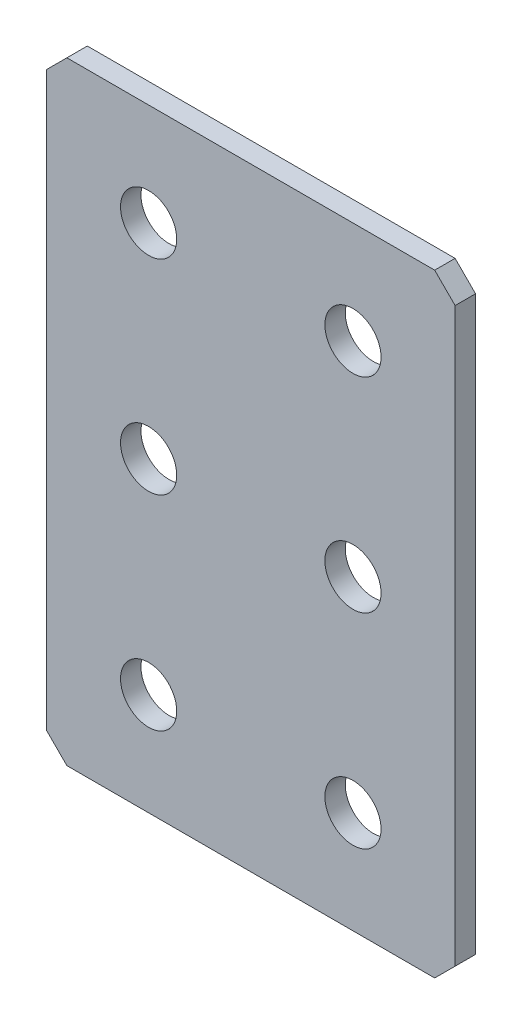
from build123d import *

# Parameters (mm, degrees)
SKETCH_1_W        = 40
SKETCH_1_H        = 60
EXTRUDE_1_DEPTH   = 2
CHAMFER_1_SIZE    = 2
HOLE_WIZARD_M51_D = 5.5


with BuildPart() as part:
    # Эскиз1 → Бобышка-Вытянуть1 (new body)
    with BuildSketch(Plane.XY):
        Rectangle(SKETCH_1_W, SKETCH_1_H)
    extrude(amount=EXTRUDE_1_DEPTH)

    # Фаска1
    chamfer_1_edges = [part.edges().sort_by_distance(p)[0] for p in [
        (20, -30, 1),
        (-20, -30, 1),
        (-20, 30, 1),
        (20, 30, 1),
    ]]
    chamfer(chamfer_1_edges, length=CHAMFER_1_SIZE)

    # Отверстие с зазором M51 (through all)
    with Locations(Plane.XY.offset(2)):
        with Locations((-10, 20), (10, 20), (10, 0), (-10, 0), (-10, -20), (10, -20)):
            Hole(HOLE_WIZARD_M51_D / 2)


solid = part.part
